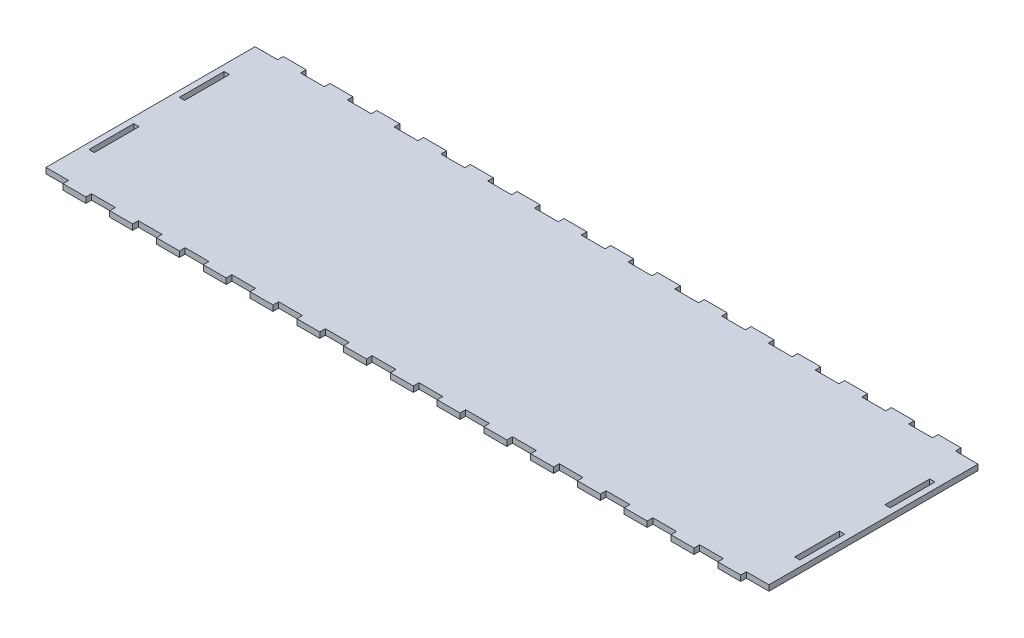
from build123d import *

# Parameters (mm, degrees)
SKETCH1_W           = 2.9718
SKETCH1_H           = 25.1968
BOSS_EXTRUDE1_DEPTH = 3.175


with BuildPart() as part:
    # Sketch1 → Boss-Extrude1 (new body)
    with BuildSketch(Plane(origin=(0, 0, 0), x_dir=(1, 0, 0), z_dir=(0, 1, 0))):
        Polygon((-137.987314286, 58.785125), (-151.391257143, 58.785125), (-151.391257143, 61.960125), (-164.294457143, 61.960125), (-164.294457143, 58.785125), (-177.6984, 58.785125), (-177.6984, 61.960125), (-190.6016, 61.960125), (-190.6016, 58.785125), (-203.3016, 58.785125), (-203.3016, -58.785125), (-190.6016, -58.785125), (-190.6016, -61.960125), (-177.6984, -61.960125), (-177.6984, -58.785125), (-164.294457143, -58.785125), (-164.294457143, -61.960125), (-151.391257143, -61.960125), (-151.391257143, -58.785125), (-137.987314286, -58.785125), (-137.987314286, -61.960125), (-125.084114286, -61.960125), (-125.084114286, -58.785125), (-111.680171429, -58.785125), (-111.680171429, -61.960125), (-98.776971429, -61.960125), (-98.776971429, -58.785125), (-85.373028571, -58.785125), (-85.373028571, -61.960125), (-72.469828571, -61.960125), (-72.469828571, -58.785125), (-59.065885714, -58.785125), (-59.065885714, -61.960125), (-46.162685714, -61.960125), (-46.162685714, -58.785125), (-32.758742857, -58.785125), (-32.758742857, -61.960125), (-19.855542857, -61.960125), (-19.855542857, -58.785125), (-6.4516, -58.785125), (-6.4516, -61.960125), (6.4516, -61.960125), (6.4516, -58.785125), (19.855542857, -58.785125), (19.855542857, -61.960125), (32.758742857, -61.960125), (32.758742857, -58.785125), (46.162685714, -58.785125), (46.162685714, -61.960125), (59.065885714, -61.960125), (59.065885714, -58.785125), (72.469828571, -58.785125), (72.469828571, -61.960125), (85.373028571, -61.960125), (85.373028571, -58.785125), (98.776971429, -58.785125), (98.776971429, -61.960125), (111.680171429, -61.960125), (111.680171429, -58.785125), (125.084114286, -58.785125), (125.084114286, -61.960125), (137.987314286, -61.960125), (137.987314286, -58.785125), (151.391257143, -58.785125), (151.391257143, -61.960125), (164.294457143, -61.960125), (164.294457143, -58.785125), (177.6984, -58.785125), (177.6984, -61.960125), (190.6016, -61.960125), (190.6016, -58.785125), (203.3016, -58.785125), (203.3016, 58.785125), (190.6016, 58.785125), (190.6016, 61.960125), (177.6984, 61.960125), (177.6984, 58.785125), (164.294457143, 58.785125), (164.294457143, 61.960125), (151.391257143, 61.960125), (151.391257143, 58.785125), (137.987314286, 58.785125), (137.987314286, 61.960125), (125.084114286, 61.960125), (125.084114286, 58.785125), (111.680171429, 58.785125), (111.680171429, 61.960125), (98.776971429, 61.960125), (98.776971429, 58.785125), (85.373028571, 58.785125), (85.373028571, 61.960125), (72.469828571, 61.960125), (72.469828571, 58.785125), (59.065885714, 58.785125), (59.065885714, 61.960125), (46.162685714, 61.960125), (46.162685714, 58.785125), (32.758742857, 58.785125), (32.758742857, 61.960125), (19.855542857, 61.960125), (19.855542857, 58.785125), (6.4516, 58.785125), (6.4516, 61.960125), (-6.4516, 61.960125), (-6.4516, 58.785125), (-19.855542857, 58.785125), (-19.855542857, 61.960125), (-32.758742857, 61.960125), (-32.758742857, 58.785125), (-46.162685714, 58.785125), (-46.162685714, 61.960125), (-59.065885714, 61.960125), (-59.065885714, 58.785125), (-72.469828571, 58.785125), (-72.469828571, 61.960125), (-85.373028571, 61.960125), (-85.373028571, 58.785125), (-98.776971429, 58.785125), (-98.776971429, 61.960125), (-111.680171429, 61.960125), (-111.680171429, 58.785125), (-125.084114286, 58.785125), (-125.084114286, 61.960125), (-137.987314286, 61.960125), align=None)
        with Locations((-198.4375, 25.4)):
            Rectangle(SKETCH1_W, SKETCH1_H, mode=Mode.SUBTRACT)
        with Locations((-198.4375, -25.4)):
            Rectangle(SKETCH1_W, SKETCH1_H, mode=Mode.SUBTRACT)
        with Locations((198.4375, 25.4)):
            Rectangle(SKETCH1_W, SKETCH1_H, mode=Mode.SUBTRACT)
        with Locations((198.4375, -25.4)):
            Rectangle(SKETCH1_W, SKETCH1_H, mode=Mode.SUBTRACT)
    extrude(amount=BOSS_EXTRUDE1_DEPTH)


solid = part.part
